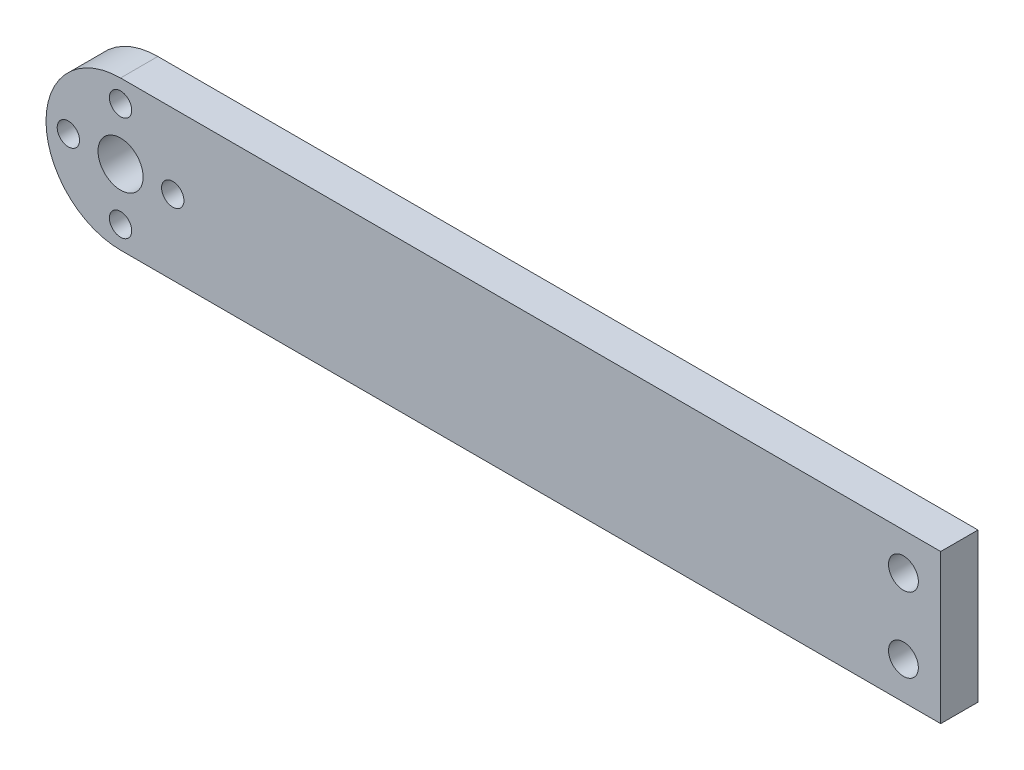
from build123d import *

# Parameters (mm, degrees)
SKETCH1_W           = 120
SKETCH1_H           = 20
BOSS_EXTRUDE1_DEPTH = 5
SKETCH2_R           = 1.5
SKETCH2_R_2         = 3.025
CUT_EXTRUDE1_DEPTH  = 10
CUT_EXTRUDE2_DEPTH  = 10
SKETCH5_R           = 2
CUT_EXTRUDE3_DEPTH  = 10


with BuildPart() as part:
    # Sketch1 → Boss-Extrude1 (new body)
    with BuildSketch(Plane.XY):
        with Locations((60, 10)):
            Rectangle(SKETCH1_W, SKETCH1_H)
    extrude(amount=BOSS_EXTRUDE1_DEPTH)

    # Sketch2 → Cut-Extrude1 (cut)
    with BuildSketch(Plane.XY.offset(5)):
        with Locations((10, 17)):
            Circle(SKETCH2_R)
        with Locations((10, 10)):
            Circle(SKETCH2_R_2)
        with Locations((17, 10)):
            Circle(SKETCH2_R)
        with Locations((10, 3)):
            Circle(SKETCH2_R)
        with Locations((3, 10)):
            Circle(SKETCH2_R)
    extrude(amount=-CUT_EXTRUDE1_DEPTH, mode=Mode.SUBTRACT)

    # Sketch3 → Cut-Extrude2 (cut)
    with BuildSketch(Plane.XY.offset(5)):
        with BuildLine():
            Line((10, 30), (10, 20))
            ThreePointArc((10, 20), (0, 10), (10, 0))
            Line((10, 0), (10, -10))
            ThreePointArc((10, -10), (-10, 10), (10, 30))
        make_face()
    extrude(amount=-CUT_EXTRUDE2_DEPTH, mode=Mode.SUBTRACT)

    # Sketch5 → Cut-Extrude3 (cut)
    with BuildSketch(Plane.XY.offset(5)):
        with Locations((115, 15)):
            Circle(SKETCH5_R)
        with Locations((115, 5)):
            Circle(SKETCH5_R)
    extrude(amount=-CUT_EXTRUDE3_DEPTH, mode=Mode.SUBTRACT)


solid = part.part
